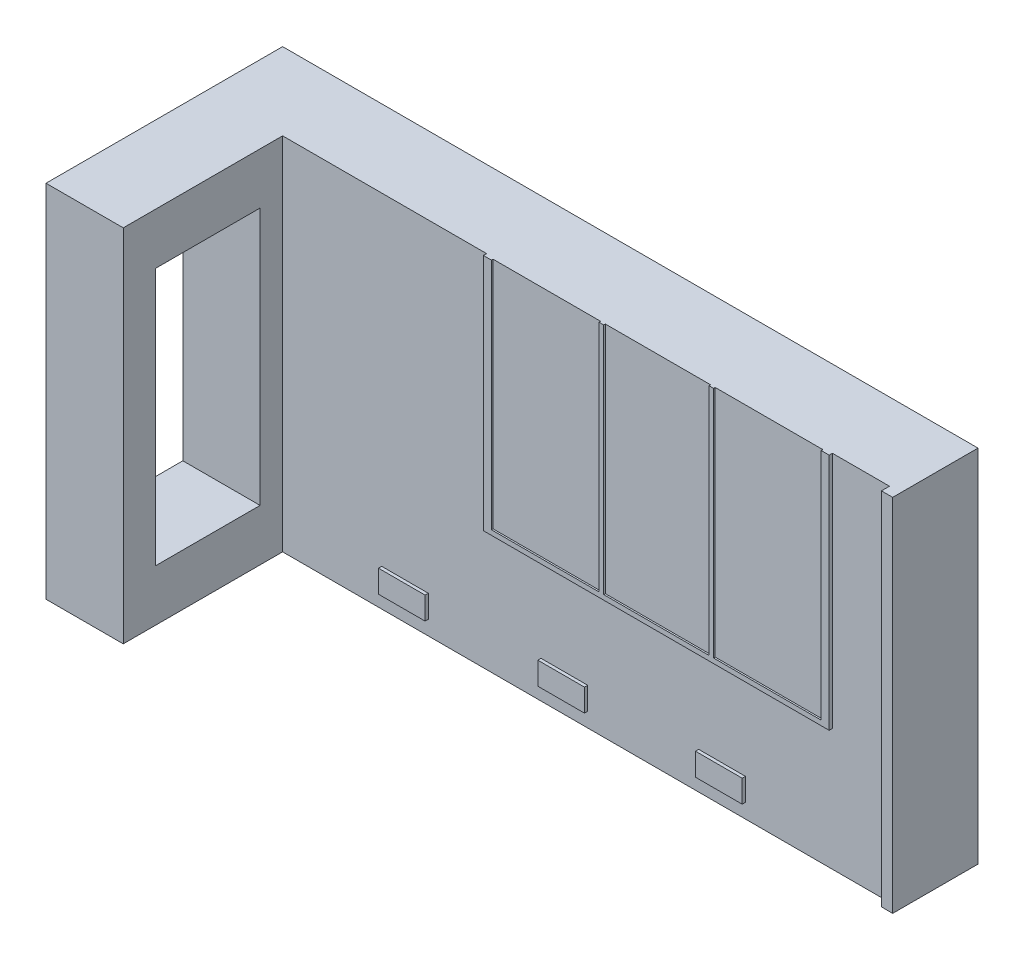
from build123d import *

# Parameters (mm, degrees)
HOUSE_EXTRUDE_Y_DEPTH        = 2842.753046323
DOOR_W                       = 825.5
DOOR_H                       = 2032
DOOR_CUT_X_DEPTH             = 609.6
WINDOW_W                     = 38.1
WINDOW_H                     = 1842.537075404
WINDOW_FRAME_EXTRUDE_Z_DEPTH = 25.4
WINDOW_3_W                   = 848.102040266
WINDOW_3_H                   = 1842.537075404
WINDOW_3_W_2                 = 829.052040266
WINDOW_GLASS_EXTRUDE_Z_DEPTH = 12.7
DRAIN_PIPE_W                 = 88.9
DRAIN_PIPE_H                 = 2842.753046323
DRAIN_PIPE_EXTRUDE_Z_DEPTH   = 63.5
VENTS_W                      = 368.3
VENTS_H                      = 177.8
VENTS_EXTRUDE_Z_DEPTH        = 25.4


with BuildPart() as part:
    # Wall Footprint → House Extrude _Y (new body)
    with BuildSketch(Plane(origin=(0, 0, 0), x_dir=(1, 0, 0), z_dir=(0, 1, 0))):
        Polygon((-205.711590821, 250.340578873), (4671.088409179, 250.340578873), (4671.088409179, 859.940578873), (-815.311590821, 859.940578873), (-815.311590821, -1006.959421127), (-205.711590821, -1006.959421127), align=None)
    extrude(amount=HOUSE_EXTRUDE_Y_DEPTH)

    # Door → Door Cut -X (cut)
    with BuildSketch(Plane(origin=(-205.711590821, 0, 0), x_dir=(0, 0, -1), z_dir=(1, 0, 0))):
        with Locations((-340.209421127, 1422.4)):
            Rectangle(DOOR_W, DOOR_H)
    extrude(amount=-DOOR_CUT_X_DEPTH, mode=Mode.SUBTRACT)

    # Window → Window Frame Extrude _Z (add)
    with BuildSketch(Plane.XY.offset(-250.340578873)):
        Polygon((1403.438613425, 2842.753046323), (1403.438613425, 962.115970919), (4131.894734223, 962.115970919), (4131.894734223, 2842.753046323), (4068.394734223, 2842.753046323), (4068.394734223, 1000.215970919), (3220.292693957, 1000.215970919), (3182.192693957, 1000.215970919), (2353.140653691, 1000.215970919), (2315.040653691, 1000.215970919), (1466.938613425, 1000.215970919), (1466.938613425, 2842.753046323), align=None)
        with Locations((2334.090653691, 1921.484508621)):
            Rectangle(WINDOW_W, WINDOW_H)
        with Locations((3201.242693957, 1921.484508621)):
            Rectangle(WINDOW_W, WINDOW_H)
    extrude(amount=WINDOW_FRAME_EXTRUDE_Z_DEPTH)

    # Window_3 → Window Glass Extrude _Z (add)
    with BuildSketch(Plane.XY.offset(-250.340578873)):
        with Locations((1890.989633558, 1921.484508621)):
            Rectangle(WINDOW_3_W, WINDOW_3_H)
        with Locations((2767.666673824, 1921.484508621)):
            Rectangle(WINDOW_3_W_2, WINDOW_3_H)
        with Locations((3644.34371409, 1921.484508621)):
            Rectangle(WINDOW_3_W, WINDOW_3_H)
    extrude(amount=WINDOW_GLASS_EXTRUDE_Z_DEPTH)

    # Drain Pipe → Drain Pipe Extrude _Z (add)
    with BuildSketch(Plane.XY.offset(-250.340578873)):
        with Locations((4626.638409179, 1421.376523162)):
            Rectangle(DRAIN_PIPE_W, DRAIN_PIPE_H)
    extrude(amount=DRAIN_PIPE_EXTRUDE_Z_DEPTH)

    # Vents → Vents Extrude _Z (add)
    with BuildSketch(Plane.XY.offset(-250.340578873)):
        with Locations((3261.388409179, 203.2)):
            Rectangle(VENTS_W, VENTS_H)
        with Locations((2016.788409179, 203.2)):
            Rectangle(VENTS_W, VENTS_H)
        with Locations((759.488409179, 203.2)):
            Rectangle(VENTS_W, VENTS_H)
    extrude(amount=VENTS_EXTRUDE_Z_DEPTH)


solid = part.part
